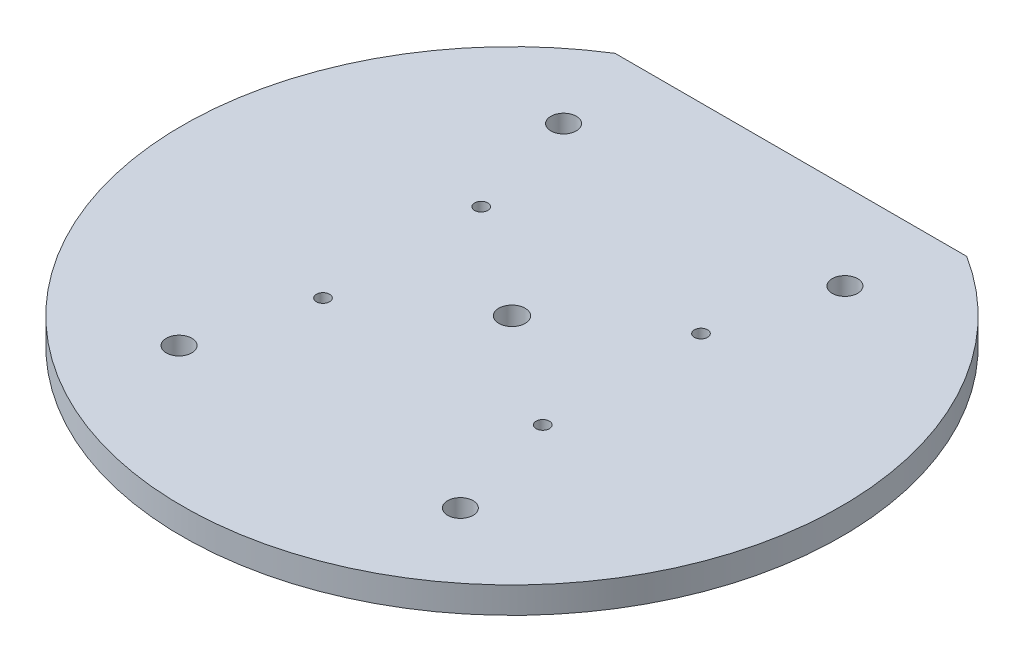
from build123d import *

# Parameters (mm, degrees)
SKETCH1_R           = 75
BOSS_EXTRUDE1_DEPTH = 6
SKETCH2_R           = 2.9
SKETCH2_R_2         = 3
SKETCH2_R_3         = 1.5
SKETCH2_W           = 80
SKETCH2_H           = 23.30375559
CUT_EXTRUDE1_DEPTH  = 6


with BuildPart() as part:
    # Sketch1 → Boss-Extrude1 (new body)
    with BuildSketch(Plane(origin=(0, 0, 0), x_dir=(1, 0, 0), z_dir=(0, 1, 0))):
        Circle(SKETCH1_R)
    extrude(amount=BOSS_EXTRUDE1_DEPTH)

    # Sketch2 → Cut-Extrude1 (cut)
    with BuildSketch(Plane(origin=(0, 6, 0), x_dir=(1, 0, 0), z_dir=(0, 1, 0))):
        with Locations((-32, 43.742887702)):
            Circle(SKETCH2_R)
        with Locations((32, 43.742887702)):
            Circle(SKETCH2_R)
        Circle(SKETCH2_R_2)
        with Locations((-32, -43.742887702)):
            Circle(SKETCH2_R)
        with Locations((32, -43.742887702)):
            Circle(SKETCH2_R)
        with Locations((25, 18)):
            Circle(SKETCH2_R_3)
        with Locations((-25, 18)):
            Circle(SKETCH2_R_3)
        with Locations((-25, -18)):
            Circle(SKETCH2_R_3)
        with Locations((25, -18)):
            Circle(SKETCH2_R_3)
        with Locations((0, 75.094765497)):
            Rectangle(SKETCH2_W, SKETCH2_H)
    extrude(amount=-CUT_EXTRUDE1_DEPTH, mode=Mode.SUBTRACT)


solid = part.part
